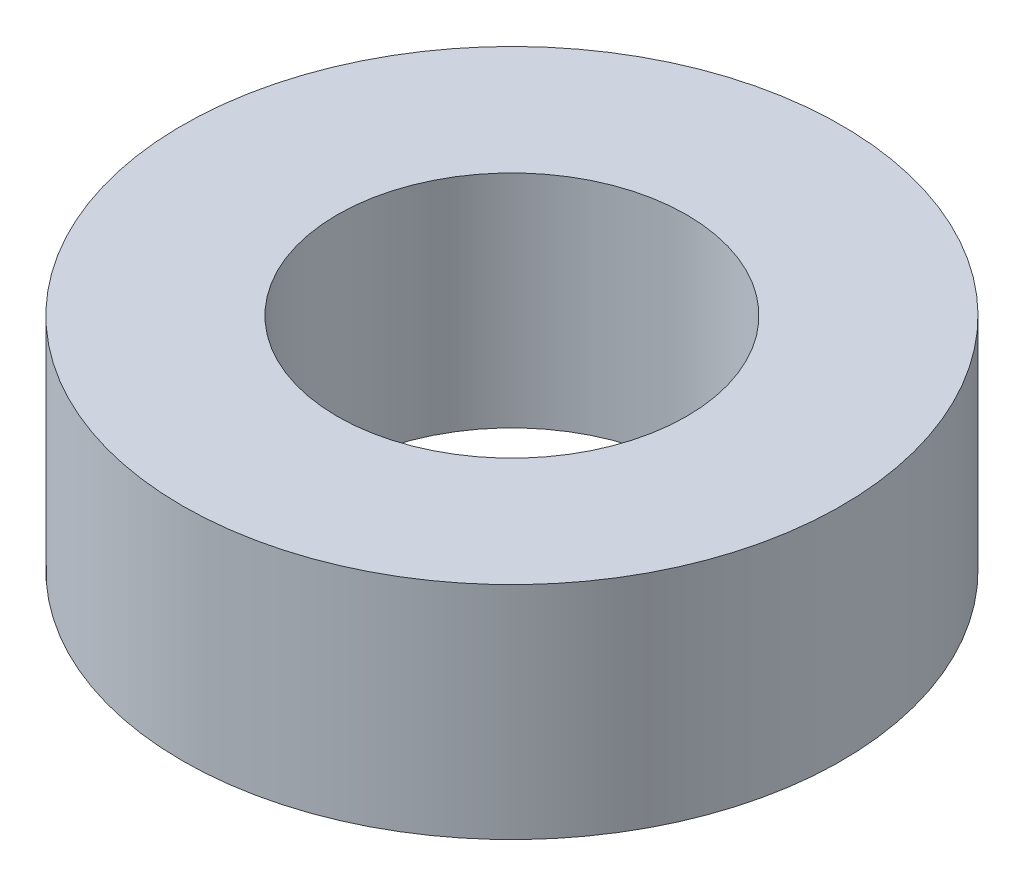
from build123d import *

# Parameters (mm, degrees)
SKETCH1_R           = 5
SKETCH1_R_2         = 2.65
BOSS_EXTRUDE1_DEPTH = 3.35


with BuildPart() as part:
    # Sketch1 → Boss-Extrude1 (new body)
    with BuildSketch(Plane(origin=(0, 0, 0), x_dir=(1, 0, 0), z_dir=(0, 1, 0))):
        Circle(SKETCH1_R)
        Circle(SKETCH1_R_2, mode=Mode.SUBTRACT)
    extrude(amount=BOSS_EXTRUDE1_DEPTH)


solid = part.part
